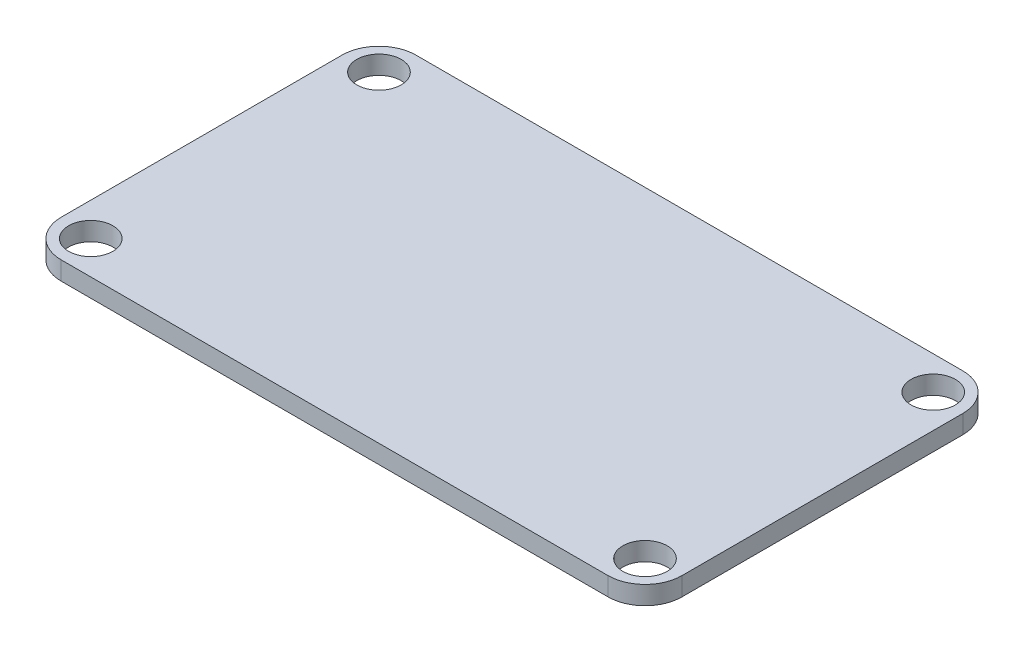
from build123d import *

# Parameters (mm, degrees)
SKETCH1_R           = 1.905
BOSS_EXTRUDE1_DEPTH = 1.5875


with BuildPart() as part:
    # Sketch1 → Boss-Extrude1 (new body)
    with BuildSketch(Plane(origin=(0, 0, 0), x_dir=(1, 0, 0), z_dir=(0, 1, 0))):
        with BuildLine():
            Line((3.175, 0), (50.165, 0))
            ThreePointArc((50.165, 0), (52.41006403, 0.92993597), (53.34, 3.175))
            Line((53.34, 3.175), (53.34, 27.305))
            ThreePointArc((53.34, 27.305), (52.41006403, 29.55006403), (50.165, 30.48))
            Line((50.165, 30.48), (3.175, 30.48))
            ThreePointArc((3.175, 30.48), (0.92993597, 29.55006403), (0, 27.305))
            Line((0, 27.305), (0, 3.175))
            ThreePointArc((0, 3.175), (0.92993597, 0.92993597), (3.175, 0))
        make_face()
        with Locations((2.8575, 2.8575)):
            Circle(SKETCH1_R, mode=Mode.SUBTRACT)
        with Locations((2.8575, 27.6225)):
            Circle(SKETCH1_R, mode=Mode.SUBTRACT)
        with Locations((50.4825, 27.6225)):
            Circle(SKETCH1_R, mode=Mode.SUBTRACT)
        with Locations((50.4825, 2.8575)):
            Circle(SKETCH1_R, mode=Mode.SUBTRACT)
    extrude(amount=BOSS_EXTRUDE1_DEPTH)


solid = part.part
